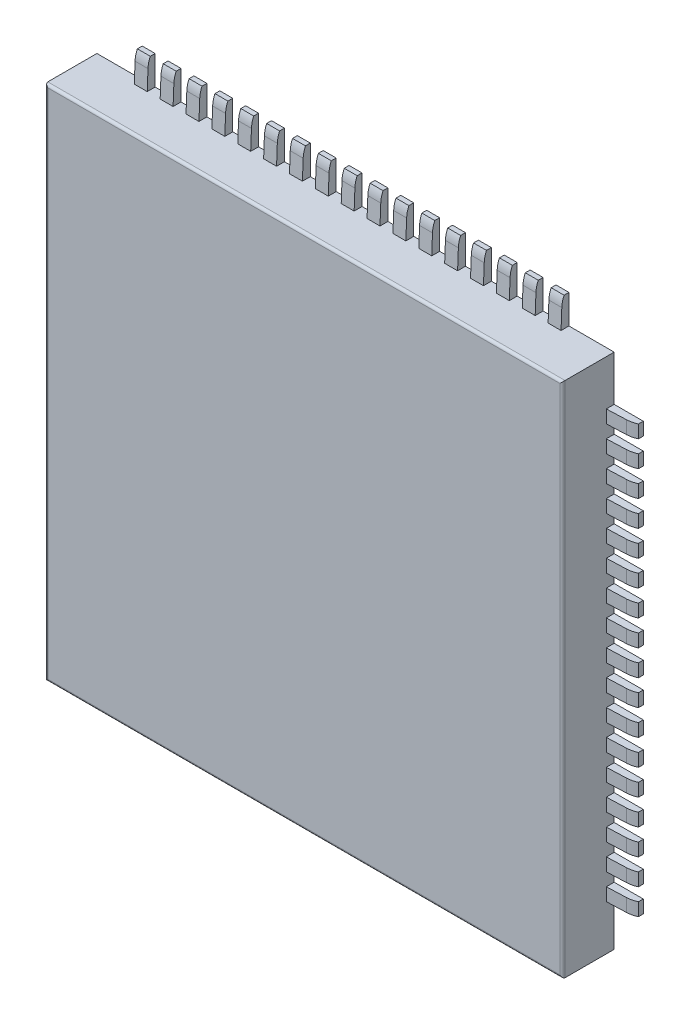
from build123d import *

# Parameters (mm, degrees)
SKETCH1_W           = 8
SKETCH1_H           = 8
BOSS_EXTRUDE1_DEPTH = 0.8
FILLET1_R           = 0.04
SKETCH3_W           = 0.2
SKETCH3_H           = 0.45
BOSS_EXTRUDE2_DEPTH = 0.15
CUT_EXTRUDE2_DEPTH  = 8.3
LPATTERN1_COUNT     = 17
LPATTERN1_PITCH     = 0.4
SKETCH5_R           = 2.5
BOSS_EXTRUDE3_DEPTH = 0.1
CIRPATTERN1_COUNT   = 4


with BuildPart() as part:
    # Sketch1 → Boss-Extrude1 (new body)
    with BuildSketch(Plane.XY):
        Rectangle(SKETCH1_W, SKETCH1_H)
    extrude(amount=BOSS_EXTRUDE1_DEPTH)

    # Fillet1
    fillet1_edges = [part.edges().sort_by_distance(p)[0] for p in [
        (4, 0, 0.8),
        (0, 4, 0.8),
        (-4, 0, 0.8),
        (0, -4, 0.8),
    ]]
    fillet(fillet1_edges, radius=FILLET1_R)


with BuildPart() as body_2:
    # Sketch3 → Boss-Extrude2 (new body)
    with BuildSketch(Plane(origin=(0, 0, 0), x_dir=(-1, 0, 0), z_dir=(0, 0, -1))):
        with Locations((3.2, -4.225)):
            Rectangle(SKETCH3_W, SKETCH3_H)
    extrude(amount=-BOSS_EXTRUDE2_DEPTH)

    # Sketch4 → Cut-Extrude2 (cut, through all)
    with BuildSketch(Plane.ZY.offset(3.3)):
        with BuildLine():
            Line((0.121893564, -4), (0.110154669, -4.301892387))
            ThreePointArc((0.110154669, -4.301892387), (0.099789952, -4.377658173), (0.075, -4.45))
            Line((0.075, -4.45), (0.272381791, -4.592230836))
            Line((0.272381791, -4.592230836), (0.293086267, -4))
            Line((0.293086267, -4), (0.121893564, -4))
        make_face()
    extrude(amount=-CUT_EXTRUDE2_DEPTH, mode=Mode.SUBTRACT)


with BuildPart() as lpattern1_1:
    # LPattern1: pattern copy
    add(body_2.part.moved(Location(Vector(1, 0, 0) * (1 * LPATTERN1_PITCH))))


with BuildPart() as lpattern1_2:
    # LPattern1: pattern copy
    add(body_2.part.moved(Location(Vector(1, 0, 0) * (2 * LPATTERN1_PITCH))))


with BuildPart() as lpattern1_3:
    # LPattern1: pattern copy
    add(body_2.part.moved(Location(Vector(1, 0, 0) * (3 * LPATTERN1_PITCH))))


with BuildPart() as lpattern1_4:
    # LPattern1: pattern copy
    add(body_2.part.moved(Location(Vector(1, 0, 0) * (4 * LPATTERN1_PITCH))))


with BuildPart() as lpattern1_5:
    # LPattern1: pattern copy
    add(body_2.part.moved(Location(Vector(1, 0, 0) * (5 * LPATTERN1_PITCH))))


with BuildPart() as lpattern1_6:
    # LPattern1: pattern copy
    add(body_2.part.moved(Location(Vector(1, 0, 0) * (6 * LPATTERN1_PITCH))))


with BuildPart() as lpattern1_7:
    # LPattern1: pattern copy
    add(body_2.part.moved(Location(Vector(1, 0, 0) * (7 * LPATTERN1_PITCH))))


with BuildPart() as lpattern1_8:
    # LPattern1: pattern copy
    add(body_2.part.moved(Location(Vector(1, 0, 0) * (8 * LPATTERN1_PITCH))))


with BuildPart() as lpattern1_9:
    # LPattern1: pattern copy
    add(body_2.part.moved(Location(Vector(1, 0, 0) * (9 * LPATTERN1_PITCH))))


with BuildPart() as lpattern1_10:
    # LPattern1: pattern copy
    add(body_2.part.moved(Location(Vector(1, 0, 0) * (10 * LPATTERN1_PITCH))))


with BuildPart() as lpattern1_11:
    # LPattern1: pattern copy
    add(body_2.part.moved(Location(Vector(1, 0, 0) * (11 * LPATTERN1_PITCH))))


with BuildPart() as lpattern1_12:
    # LPattern1: pattern copy
    add(body_2.part.moved(Location(Vector(1, 0, 0) * (12 * LPATTERN1_PITCH))))


with BuildPart() as lpattern1_13:
    # LPattern1: pattern copy
    add(body_2.part.moved(Location(Vector(1, 0, 0) * (13 * LPATTERN1_PITCH))))


with BuildPart() as lpattern1_14:
    # LPattern1: pattern copy
    add(body_2.part.moved(Location(Vector(1, 0, 0) * (14 * LPATTERN1_PITCH))))


with BuildPart() as lpattern1_15:
    # LPattern1: pattern copy
    add(body_2.part.moved(Location(Vector(1, 0, 0) * (15 * LPATTERN1_PITCH))))


with BuildPart() as lpattern1_16:
    # LPattern1: pattern copy
    add(body_2.part.moved(Location(Vector(1, 0, 0) * (16 * LPATTERN1_PITCH))))


with BuildPart() as body_19:
    # Sketch5 → Boss-Extrude3 (new body)
    with BuildSketch(Plane(origin=(0, 0, 0), x_dir=(-1, 0, 0), z_dir=(0, 0, -1))):
        Circle(SKETCH5_R)
    extrude(amount=BOSS_EXTRUDE3_DEPTH)


with BuildPart() as cirpattern1_1:
    # CirPattern1: pattern copy
    add(lpattern1_16.part.rotate(Axis((0, 0, 0), (0, 0, 1)), 1 * 360 / CIRPATTERN1_COUNT))


with BuildPart() as cirpattern1_2:
    # CirPattern1: pattern copy
    add(lpattern1_16.part.rotate(Axis((0, 0, 0), (0, 0, 1)), 2 * 360 / CIRPATTERN1_COUNT))


with BuildPart() as cirpattern1_3:
    # CirPattern1: pattern copy
    add(lpattern1_16.part.rotate(Axis((0, 0, 0), (0, 0, 1)), 3 * 360 / CIRPATTERN1_COUNT))


with BuildPart() as cirpattern1_4:
    # CirPattern1: pattern copy
    add(lpattern1_15.part.rotate(Axis((0, 0, 0), (0, 0, 1)), 1 * 360 / CIRPATTERN1_COUNT))


with BuildPart() as cirpattern1_5:
    # CirPattern1: pattern copy
    add(lpattern1_15.part.rotate(Axis((0, 0, 0), (0, 0, 1)), 2 * 360 / CIRPATTERN1_COUNT))


with BuildPart() as cirpattern1_6:
    # CirPattern1: pattern copy
    add(lpattern1_15.part.rotate(Axis((0, 0, 0), (0, 0, 1)), 3 * 360 / CIRPATTERN1_COUNT))


with BuildPart() as cirpattern1_7:
    # CirPattern1: pattern copy
    add(lpattern1_14.part.rotate(Axis((0, 0, 0), (0, 0, 1)), 1 * 360 / CIRPATTERN1_COUNT))


with BuildPart() as cirpattern1_8:
    # CirPattern1: pattern copy
    add(lpattern1_14.part.rotate(Axis((0, 0, 0), (0, 0, 1)), 2 * 360 / CIRPATTERN1_COUNT))


with BuildPart() as cirpattern1_9:
    # CirPattern1: pattern copy
    add(lpattern1_14.part.rotate(Axis((0, 0, 0), (0, 0, 1)), 3 * 360 / CIRPATTERN1_COUNT))


with BuildPart() as cirpattern1_10:
    # CirPattern1: pattern copy
    add(lpattern1_13.part.rotate(Axis((0, 0, 0), (0, 0, 1)), 1 * 360 / CIRPATTERN1_COUNT))


with BuildPart() as cirpattern1_11:
    # CirPattern1: pattern copy
    add(lpattern1_13.part.rotate(Axis((0, 0, 0), (0, 0, 1)), 2 * 360 / CIRPATTERN1_COUNT))


with BuildPart() as cirpattern1_12:
    # CirPattern1: pattern copy
    add(lpattern1_13.part.rotate(Axis((0, 0, 0), (0, 0, 1)), 3 * 360 / CIRPATTERN1_COUNT))


with BuildPart() as cirpattern1_13:
    # CirPattern1: pattern copy
    add(lpattern1_12.part.rotate(Axis((0, 0, 0), (0, 0, 1)), 1 * 360 / CIRPATTERN1_COUNT))


with BuildPart() as cirpattern1_14:
    # CirPattern1: pattern copy
    add(lpattern1_12.part.rotate(Axis((0, 0, 0), (0, 0, 1)), 2 * 360 / CIRPATTERN1_COUNT))


with BuildPart() as cirpattern1_15:
    # CirPattern1: pattern copy
    add(lpattern1_12.part.rotate(Axis((0, 0, 0), (0, 0, 1)), 3 * 360 / CIRPATTERN1_COUNT))


with BuildPart() as cirpattern1_16:
    # CirPattern1: pattern copy
    add(lpattern1_11.part.rotate(Axis((0, 0, 0), (0, 0, 1)), 1 * 360 / CIRPATTERN1_COUNT))


with BuildPart() as cirpattern1_17:
    # CirPattern1: pattern copy
    add(lpattern1_11.part.rotate(Axis((0, 0, 0), (0, 0, 1)), 2 * 360 / CIRPATTERN1_COUNT))


with BuildPart() as cirpattern1_18:
    # CirPattern1: pattern copy
    add(lpattern1_11.part.rotate(Axis((0, 0, 0), (0, 0, 1)), 3 * 360 / CIRPATTERN1_COUNT))


with BuildPart() as cirpattern1_19:
    # CirPattern1: pattern copy
    add(lpattern1_10.part.rotate(Axis((0, 0, 0), (0, 0, 1)), 1 * 360 / CIRPATTERN1_COUNT))


with BuildPart() as cirpattern1_20:
    # CirPattern1: pattern copy
    add(lpattern1_10.part.rotate(Axis((0, 0, 0), (0, 0, 1)), 2 * 360 / CIRPATTERN1_COUNT))


with BuildPart() as cirpattern1_21:
    # CirPattern1: pattern copy
    add(lpattern1_10.part.rotate(Axis((0, 0, 0), (0, 0, 1)), 3 * 360 / CIRPATTERN1_COUNT))


with BuildPart() as cirpattern1_22:
    # CirPattern1: pattern copy
    add(lpattern1_9.part.rotate(Axis((0, 0, 0), (0, 0, 1)), 1 * 360 / CIRPATTERN1_COUNT))


with BuildPart() as cirpattern1_23:
    # CirPattern1: pattern copy
    add(lpattern1_9.part.rotate(Axis((0, 0, 0), (0, 0, 1)), 2 * 360 / CIRPATTERN1_COUNT))


with BuildPart() as cirpattern1_24:
    # CirPattern1: pattern copy
    add(lpattern1_9.part.rotate(Axis((0, 0, 0), (0, 0, 1)), 3 * 360 / CIRPATTERN1_COUNT))


with BuildPart() as cirpattern1_25:
    # CirPattern1: pattern copy
    add(body_2.part.rotate(Axis((0, 0, 0), (0, 0, 1)), 1 * 360 / CIRPATTERN1_COUNT))


with BuildPart() as cirpattern1_26:
    # CirPattern1: pattern copy
    add(body_2.part.rotate(Axis((0, 0, 0), (0, 0, 1)), 2 * 360 / CIRPATTERN1_COUNT))


with BuildPart() as cirpattern1_27:
    # CirPattern1: pattern copy
    add(body_2.part.rotate(Axis((0, 0, 0), (0, 0, 1)), 3 * 360 / CIRPATTERN1_COUNT))


with BuildPart() as cirpattern1_28:
    # CirPattern1: pattern copy
    add(lpattern1_1.part.rotate(Axis((0, 0, 0), (0, 0, 1)), 1 * 360 / CIRPATTERN1_COUNT))


with BuildPart() as cirpattern1_29:
    # CirPattern1: pattern copy
    add(lpattern1_1.part.rotate(Axis((0, 0, 0), (0, 0, 1)), 2 * 360 / CIRPATTERN1_COUNT))


with BuildPart() as cirpattern1_30:
    # CirPattern1: pattern copy
    add(lpattern1_1.part.rotate(Axis((0, 0, 0), (0, 0, 1)), 3 * 360 / CIRPATTERN1_COUNT))


with BuildPart() as cirpattern1_31:
    # CirPattern1: pattern copy
    add(lpattern1_2.part.rotate(Axis((0, 0, 0), (0, 0, 1)), 1 * 360 / CIRPATTERN1_COUNT))


with BuildPart() as cirpattern1_32:
    # CirPattern1: pattern copy
    add(lpattern1_2.part.rotate(Axis((0, 0, 0), (0, 0, 1)), 2 * 360 / CIRPATTERN1_COUNT))


with BuildPart() as cirpattern1_33:
    # CirPattern1: pattern copy
    add(lpattern1_2.part.rotate(Axis((0, 0, 0), (0, 0, 1)), 3 * 360 / CIRPATTERN1_COUNT))


with BuildPart() as cirpattern1_34:
    # CirPattern1: pattern copy
    add(lpattern1_3.part.rotate(Axis((0, 0, 0), (0, 0, 1)), 1 * 360 / CIRPATTERN1_COUNT))


with BuildPart() as cirpattern1_35:
    # CirPattern1: pattern copy
    add(lpattern1_3.part.rotate(Axis((0, 0, 0), (0, 0, 1)), 2 * 360 / CIRPATTERN1_COUNT))


with BuildPart() as cirpattern1_36:
    # CirPattern1: pattern copy
    add(lpattern1_3.part.rotate(Axis((0, 0, 0), (0, 0, 1)), 3 * 360 / CIRPATTERN1_COUNT))


with BuildPart() as cirpattern1_37:
    # CirPattern1: pattern copy
    add(lpattern1_4.part.rotate(Axis((0, 0, 0), (0, 0, 1)), 1 * 360 / CIRPATTERN1_COUNT))


with BuildPart() as cirpattern1_38:
    # CirPattern1: pattern copy
    add(lpattern1_4.part.rotate(Axis((0, 0, 0), (0, 0, 1)), 2 * 360 / CIRPATTERN1_COUNT))


with BuildPart() as cirpattern1_39:
    # CirPattern1: pattern copy
    add(lpattern1_4.part.rotate(Axis((0, 0, 0), (0, 0, 1)), 3 * 360 / CIRPATTERN1_COUNT))


with BuildPart() as cirpattern1_40:
    # CirPattern1: pattern copy
    add(lpattern1_5.part.rotate(Axis((0, 0, 0), (0, 0, 1)), 1 * 360 / CIRPATTERN1_COUNT))


with BuildPart() as cirpattern1_41:
    # CirPattern1: pattern copy
    add(lpattern1_5.part.rotate(Axis((0, 0, 0), (0, 0, 1)), 2 * 360 / CIRPATTERN1_COUNT))


with BuildPart() as cirpattern1_42:
    # CirPattern1: pattern copy
    add(lpattern1_5.part.rotate(Axis((0, 0, 0), (0, 0, 1)), 3 * 360 / CIRPATTERN1_COUNT))


with BuildPart() as cirpattern1_43:
    # CirPattern1: pattern copy
    add(lpattern1_6.part.rotate(Axis((0, 0, 0), (0, 0, 1)), 1 * 360 / CIRPATTERN1_COUNT))


with BuildPart() as cirpattern1_44:
    # CirPattern1: pattern copy
    add(lpattern1_6.part.rotate(Axis((0, 0, 0), (0, 0, 1)), 2 * 360 / CIRPATTERN1_COUNT))


with BuildPart() as cirpattern1_45:
    # CirPattern1: pattern copy
    add(lpattern1_6.part.rotate(Axis((0, 0, 0), (0, 0, 1)), 3 * 360 / CIRPATTERN1_COUNT))


with BuildPart() as cirpattern1_46:
    # CirPattern1: pattern copy
    add(lpattern1_7.part.rotate(Axis((0, 0, 0), (0, 0, 1)), 1 * 360 / CIRPATTERN1_COUNT))


with BuildPart() as cirpattern1_47:
    # CirPattern1: pattern copy
    add(lpattern1_7.part.rotate(Axis((0, 0, 0), (0, 0, 1)), 2 * 360 / CIRPATTERN1_COUNT))


with BuildPart() as cirpattern1_48:
    # CirPattern1: pattern copy
    add(lpattern1_7.part.rotate(Axis((0, 0, 0), (0, 0, 1)), 3 * 360 / CIRPATTERN1_COUNT))


with BuildPart() as cirpattern1_49:
    # CirPattern1: pattern copy
    add(lpattern1_8.part.rotate(Axis((0, 0, 0), (0, 0, 1)), 1 * 360 / CIRPATTERN1_COUNT))


with BuildPart() as cirpattern1_50:
    # CirPattern1: pattern copy
    add(lpattern1_8.part.rotate(Axis((0, 0, 0), (0, 0, 1)), 2 * 360 / CIRPATTERN1_COUNT))


with BuildPart() as cirpattern1_51:
    # CirPattern1: pattern copy
    add(lpattern1_8.part.rotate(Axis((0, 0, 0), (0, 0, 1)), 3 * 360 / CIRPATTERN1_COUNT))


solid = Compound([part.part, body_2.part, lpattern1_1.part, lpattern1_2.part, lpattern1_3.part, lpattern1_4.part, lpattern1_5.part, lpattern1_6.part, lpattern1_7.part, lpattern1_8.part, lpattern1_9.part, lpattern1_10.part, lpattern1_11.part, lpattern1_12.part, lpattern1_13.part, lpattern1_14.part, lpattern1_15.part, lpattern1_16.part, body_19.part, cirpattern1_1.part, cirpattern1_2.part, cirpattern1_3.part, cirpattern1_4.part, cirpattern1_5.part, cirpattern1_6.part, cirpattern1_7.part, cirpattern1_8.part, cirpattern1_9.part, cirpattern1_10.part, cirpattern1_11.part, cirpattern1_12.part, cirpattern1_13.part, cirpattern1_14.part, cirpattern1_15.part, cirpattern1_16.part, cirpattern1_17.part, cirpattern1_18.part, cirpattern1_19.part, cirpattern1_20.part, cirpattern1_21.part, cirpattern1_22.part, cirpattern1_23.part, cirpattern1_24.part, cirpattern1_25.part, cirpattern1_26.part, cirpattern1_27.part, cirpattern1_28.part, cirpattern1_29.part, cirpattern1_30.part, cirpattern1_31.part, cirpattern1_32.part, cirpattern1_33.part, cirpattern1_34.part, cirpattern1_35.part, cirpattern1_36.part, cirpattern1_37.part, cirpattern1_38.part, cirpattern1_39.part, cirpattern1_40.part, cirpattern1_41.part, cirpattern1_42.part, cirpattern1_43.part, cirpattern1_44.part, cirpattern1_45.part, cirpattern1_46.part, cirpattern1_47.part, cirpattern1_48.part, cirpattern1_49.part, cirpattern1_50.part, cirpattern1_51.part])
